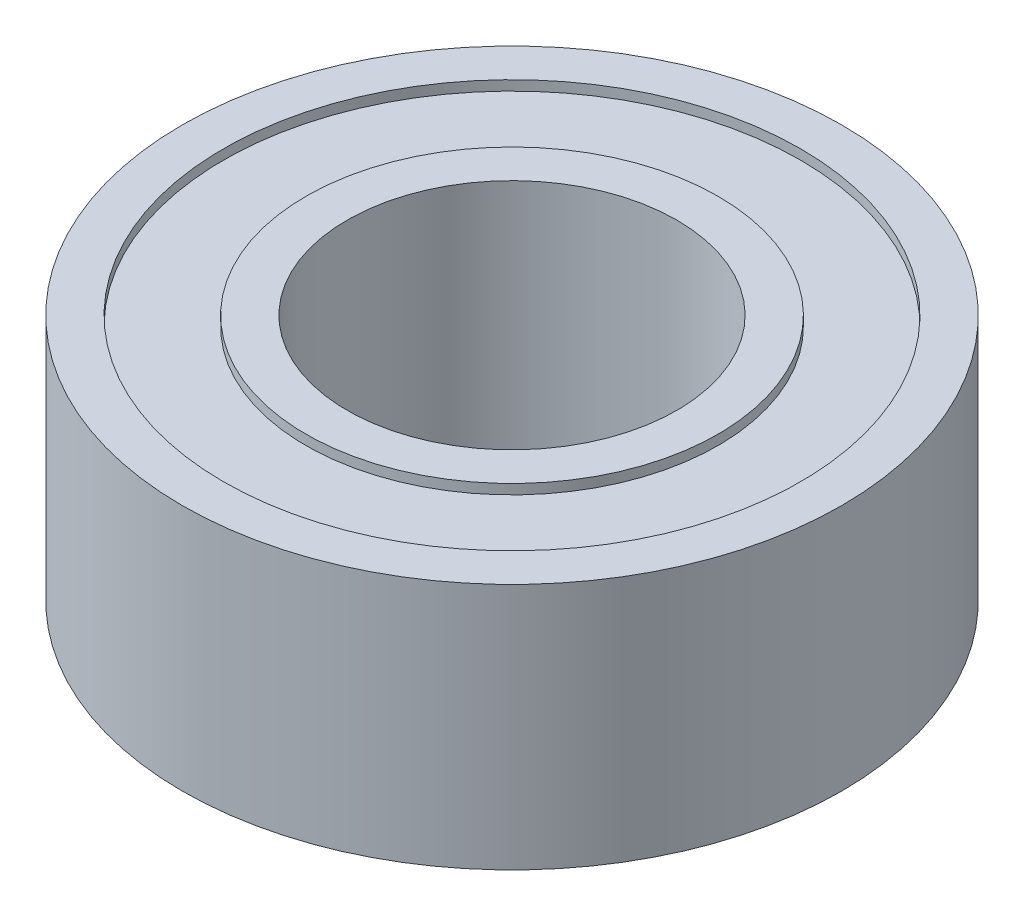
from build123d import *


with BuildPart() as part:
    # Sketch1 → Revolve1 (revolve)
    with BuildSketch(Plane.XY):
        Polygon((12.7, 9.525), (15.875, 9.525), (15.875, 8.763), (22.225, 8.763), (22.225, 9.525), (25.4, 9.525), (25.4, 0), (12.7, 0), align=None)
    revolve(axis=Axis((0, 0, 0), (0, 1, 0)))

    # Mirror1: part across plane


with BuildPart() as part_1:
    add(part.part)
    add(part.part.mirror(Plane.ZX))


solid = part_1.part
